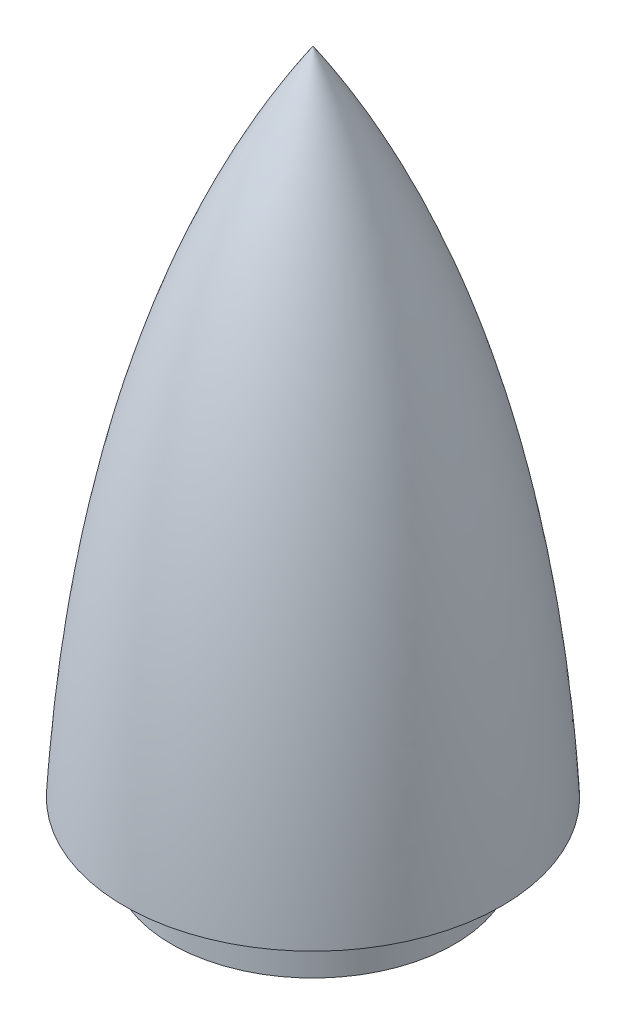
from build123d import *


with BuildPart() as part:
    # Sketch1 → Revolve1 (revolve)
    with BuildSketch(Plane.XY):
        with BuildLine():
            Line((0, 74.992200594), (0, -0.007799406))
            Line((0, -0.007799406), (15, -0.007799406))
            Line((15, -0.007799406), (15, 5.992200594))
            Line((15, 5.992200594), (20, 5.992200594))
            add(Edge.make_bspline(
                [(0, 74.992200594), (17.63371232, 48.525810358), (20, 5.992200594)],
                knots=[0, 0, 0, 0.771738447, 0.771738447, 0.771738447], degree=2))
        make_face()
    revolve(axis=Axis((0, 74.992200594, 0), (0, -1, 0)))


solid = part.part
